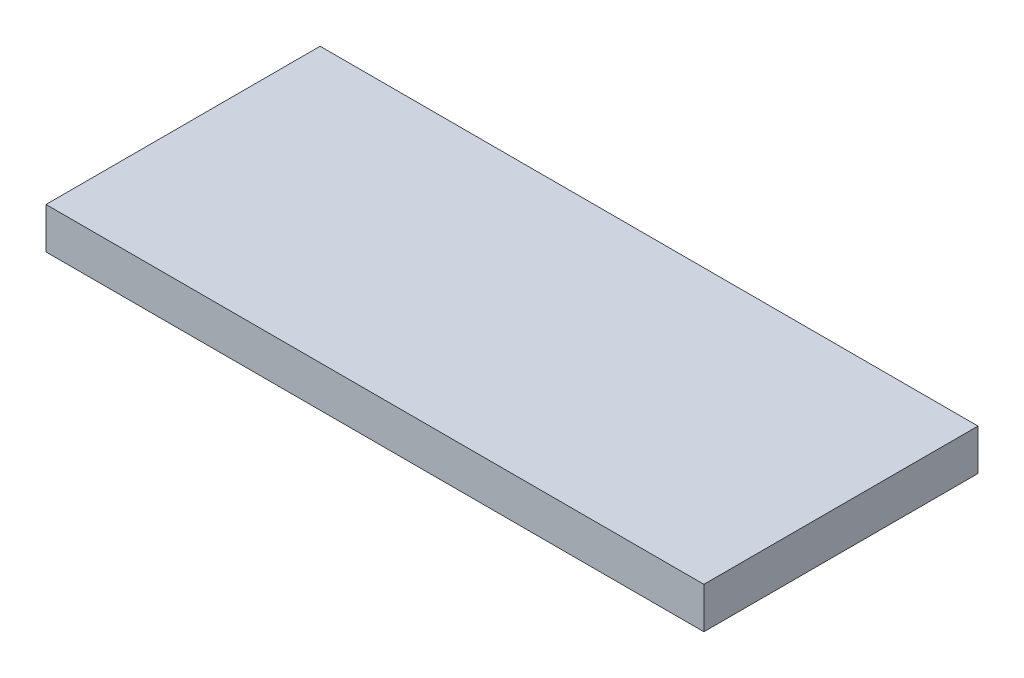
from build123d import *

# Parameters (mm, degrees)
SKETCH1_W           = 48
SKETCH1_H           = 20
BOSS_EXTRUDE1_DEPTH = 3


with BuildPart() as part:
    # Sketch1 → Boss-Extrude1 (new body)
    with BuildSketch(Plane(origin=(0, 0, 0), x_dir=(1, 0, 0), z_dir=(0, 1, 0))):
        Rectangle(SKETCH1_W, SKETCH1_H)
    extrude(amount=BOSS_EXTRUDE1_DEPTH)


solid = part.part
